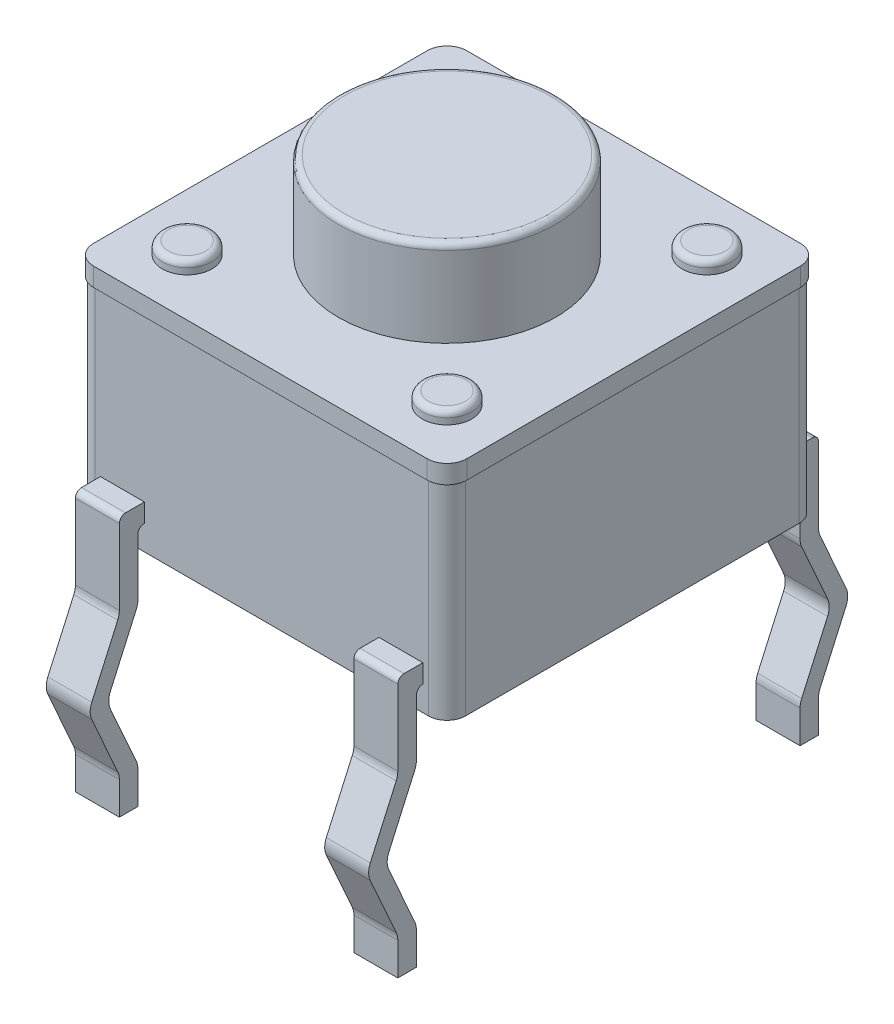
from build123d import *

# Parameters (mm, degrees)
RESSALTO_EXTRUS_O1_DEPTH = 3.61
ESBO_O2_R                = 1.755
RESSALTO_EXTRUS_O2_DEPTH = 1.4
FILETE1_R                = 0.1
ESBO_O3_R                = 0.4
RESSALTO_EXTRUS_O3_DEPTH = 0.2
FILETE2_R                = 0.1
RESSALTO_EXTRUS_O4_DEPTH = 0.3
RESSALTO_EXTRUS_O5_DEPTH = 0.355
ESPELHAR2_COPY_1_DEPTH   = 0.355


with BuildPart() as part:
    # Esboço1 → Ressalto-extrusão1 (new body)
    with BuildSketch(Plane(origin=(0, 0, 0), x_dir=(1, 0, 0), z_dir=(0, 1, 0))):
        with BuildLine():
            Line((-2.695, 2.995), (2.695, 2.995))
            ThreePointArc((2.695, 2.995), (2.907132034, 2.907132034), (2.995, 2.695))
            Line((2.995, 2.695), (2.995, -2.695))
            ThreePointArc((2.995, -2.695), (2.907132034, -2.907132034), (2.695, -2.995))
            Line((2.695, -2.995), (-2.695, -2.995))
            ThreePointArc((-2.695, -2.995), (-2.907132034, -2.907132034), (-2.995, -2.695))
            Line((-2.995, -2.695), (-2.995, 2.695))
            ThreePointArc((-2.995, 2.695), (-2.907132034, 2.907132034), (-2.695, 2.995))
        make_face()
    extrude(amount=RESSALTO_EXTRUS_O1_DEPTH)



with BuildPart() as body_2:
    # Esboço2 → Ressalto-extrusão2 (new body)
    with BuildSketch(Plane(origin=(0, 3.61, 0), x_dir=(1, 0, 0), z_dir=(0, 1, 0))):
        with Locations(Location((0, 0, 0), (0, 0, 270))):
            Circle(ESBO_O2_R)
    extrude(amount=RESSALTO_EXTRUS_O2_DEPTH)

    # Filete1
    filete1_edges = [body_2.edges().sort_by_distance(p)[0] for p in [
        (0, 5.01, -1.755),
    ]]
    fillet(filete1_edges, radius=FILETE1_R)


with BuildPart() as part_1:
    add(part.part)

    add(body_2.part)  # Ressalto-extrusão3 merges body 2
    # Esboço3 → Ressalto-extrusão3 (add)
    with BuildSketch(Plane(origin=(0, 3.61, 0), x_dir=(1, 0, 0), z_dir=(0, 1, 0))):
        with Locations(Location((-2.1, 2.1, 0), (0, 0, 270))):
            Circle(ESBO_O3_R)
        with Locations(Location((2.1, 2.1, 0), (0, 0, 90))):
            Circle(ESBO_O3_R)
        with Locations(Location((2.1, -2.1, 0), (0, 0, 270))):
            Circle(ESBO_O3_R)
        with Locations(Location((-2.1, -2.1, 0), (0, 0, 90))):
            Circle(ESBO_O3_R)
    extrude(amount=RESSALTO_EXTRUS_O3_DEPTH)

    # Filete2
    filete2_edges = [part_1.edges().sort_by_distance(p)[0] for p in [
        (-2.1, 3.81, -2.5),
        (2.1, 3.81, -1.7),
        (2.1, 3.81, 1.7),
        (-2.1, 3.81, 2.5),
    ]]
    fillet(filete2_edges, radius=FILETE2_R)

    # Esboço4 → Ressalto-extrusão4 (add)
    with BuildSketch(Plane(origin=(0, 3.61, 0), x_dir=(1, 0, 0), z_dir=(0, 1, 0))):
        with BuildLine():
            Line((-2.695, -3.015), (2.695, -3.015))
            ThreePointArc((2.695, -3.015), (2.92127417, -2.92127417), (3.015, -2.695))
            Line((3.015, -2.695), (3.015, 2.695))
            ThreePointArc((3.015, 2.695), (2.92127417, 2.92127417), (2.695, 3.015))
            Line((2.695, 3.015), (-2.695, 3.015))
            ThreePointArc((-2.695, 3.015), (-2.92127417, 2.92127417), (-3.015, 2.695))
            Line((-3.015, 2.695), (-3.015, -2.695))
            ThreePointArc((-3.015, -2.695), (-2.92127417, -2.92127417), (-2.695, -3.015))
        make_face()
    extrude(amount=-RESSALTO_EXTRUS_O4_DEPTH)

    # Esboço5 → Ressalto-extrusão5 (add, symmetric)
    with BuildSketch(Plane(origin=(2.25, 0, 0), x_dir=(0, 0, -1), z_dir=(1, 0, 0))):
        with BuildLine():
            Line((2.995, 0.4), (3, 0.4))
            ThreePointArc((3, 0.4), (3.070710678, 0.370710678), (3.1, 0.3))
            Line((3.1, 0.3), (3.1, -0.616076091))
            ThreePointArc((3.1, -0.616076091), (3.106586972, -0.67859645), (3.126058635, -0.738371343))
            Line((3.126058635, -0.738371343), (3.545403905, -1.677704748))
            ThreePointArc((3.545403905, -1.677704748), (3.571462541, -1.8), (3.545403905, -1.922295252))
            Line((3.545403905, -1.922295252), (3.126058635, -2.861628657))
            ThreePointArc((3.126058635, -2.861628657), (3.106586972, -2.92140355), (3.1, -2.983923909))
            Line((3.1, -2.983923909), (3.1, -3.51))
            Line((3.1, -3.51), (3.4, -3.51))
            Line((3.4, -3.51), (3.4, -2.983923909))
            ThreePointArc((3.4, -2.983923909), (3.406586972, -2.92140355), (3.426058635, -2.861628657))
            Line((3.426058635, -2.861628657), (3.845403905, -1.922295252))
            ThreePointArc((3.845403905, -1.922295252), (3.871462541, -1.8), (3.845403905, -1.677704748))
            Line((3.845403905, -1.677704748), (3.426058635, -0.738371343))
            ThreePointArc((3.426058635, -0.738371343), (3.406586972, -0.67859645), (3.4, -0.616076091))
            Line((3.4, -0.616076091), (3.4, 0.6))
            ThreePointArc((3.4, 0.6), (3.370710678, 0.670710678), (3.3, 0.7))
            Line((3.3, 0.7), (2.995, 0.7))
            Line((2.995, 0.7), (2.995, 0.4))
        make_face()
    ressalto_extrus_o5 = extrude(amount=RESSALTO_EXTRUS_O5_DEPTH, both=True)

    # Espelhar1: Ressalto-extrusão5 across plane
    add(ressalto_extrus_o5.mirror(Plane(origin=(0, 0, 0), x_dir=(0, 0, 1), z_dir=(1, 0, 0))))

    # Espelhar2: Ressalto-extrusão5 across plane
    add(ressalto_extrus_o5.mirror(Plane.XY))

    # Espelhar2 copy 1 sketch → Espelhar2 copy 1 (add, symmetric)
    with BuildSketch(Plane.ZY.offset(2.25)):
        with BuildLine():
            Line((2.995, 0.4), (3, 0.4))
            ThreePointArc((3, 0.4), (3.070710678, 0.370710678), (3.1, 0.3))
            Line((3.1, 0.3), (3.1, -0.616076091))
            ThreePointArc((3.1, -0.616076091), (3.106586972, -0.67859645), (3.126058635, -0.738371343))
            Line((3.126058635, -0.738371343), (3.545403905, -1.677704748))
            ThreePointArc((3.545403905, -1.677704748), (3.571462541, -1.8), (3.545403905, -1.922295252))
            Line((3.545403905, -1.922295252), (3.126058635, -2.861628657))
            ThreePointArc((3.126058635, -2.861628657), (3.106586972, -2.92140355), (3.1, -2.983923909))
            Line((3.1, -2.983923909), (3.1, -3.51))
            Line((3.1, -3.51), (3.4, -3.51))
            Line((3.4, -3.51), (3.4, -2.983923909))
            ThreePointArc((3.4, -2.983923909), (3.406586972, -2.92140355), (3.426058635, -2.861628657))
            Line((3.426058635, -2.861628657), (3.845403905, -1.922295252))
            ThreePointArc((3.845403905, -1.922295252), (3.871462541, -1.8), (3.845403905, -1.677704748))
            Line((3.845403905, -1.677704748), (3.426058635, -0.738371343))
            ThreePointArc((3.426058635, -0.738371343), (3.406586972, -0.67859645), (3.4, -0.616076091))
            Line((3.4, -0.616076091), (3.4, 0.6))
            ThreePointArc((3.4, 0.6), (3.370710678, 0.670710678), (3.3, 0.7))
            Line((3.3, 0.7), (2.995, 0.7))
            Line((2.995, 0.7), (2.995, 0.4))
        make_face()
    extrude(amount=ESPELHAR2_COPY_1_DEPTH, both=True)


solid = part_1.part
